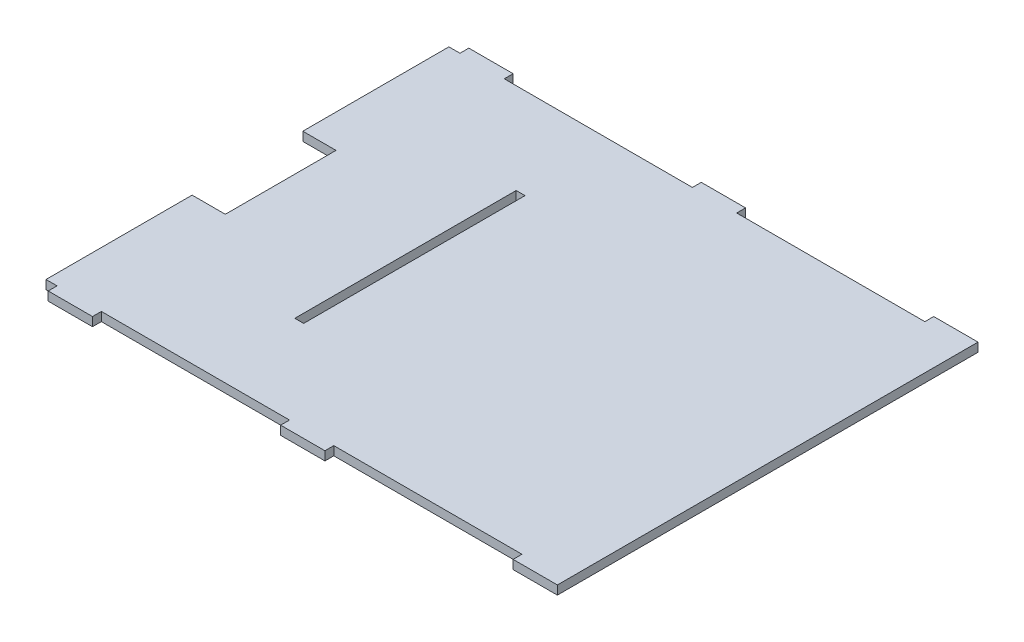
from build123d import *

# Parameters (mm, degrees)
SKETCH1_W           = 4
SKETCH1_H           = 100
BOSS_EXTRUDE1_DEPTH = 4
SKETCH2_W           = 30
SKETCH2_H           = 50
CUT_EXTRUDE1_DEPTH  = 10


with BuildPart() as part:
    # Sketch1 → Boss-Extrude1 (new body)
    with BuildSketch(Plane(origin=(0, 0, 0), x_dir=(1, 0, 0), z_dir=(0, 1, 0))):
        Polygon((-112.5, 94), (-92.5, 94), (-92.5, 90), (-7.5, 90), (-7.5, 94), (12.5, 94), (12.5, 90), (97.5, 90), (97.5, 94), (117.5, 94), (117.5, -96), (97.5, -96), (97.5, -92), (12.5, -92), (12.5, -96), (-7.5, -96), (-7.5, -92), (-92.5, -92), (-92.5, -96), (-112.5, -96), (-112.5, -92), (-117.5, -92), (-117.5, 90), (-112.5, 90), align=None)
        with Locations((-44.11, -1)):
            Rectangle(SKETCH1_W, SKETCH1_H, mode=Mode.SUBTRACT)
    extrude(amount=BOSS_EXTRUDE1_DEPTH)

    # Sketch2 → Cut-Extrude1 (cut)
    with BuildSketch(Plane(origin=(0, 4, 0), x_dir=(1, 0, 0), z_dir=(0, 1, 0))):
        with Locations((-117.5, -1)):
            Rectangle(SKETCH2_W, SKETCH2_H)
    extrude(amount=-CUT_EXTRUDE1_DEPTH, mode=Mode.SUBTRACT)


solid = part.part
